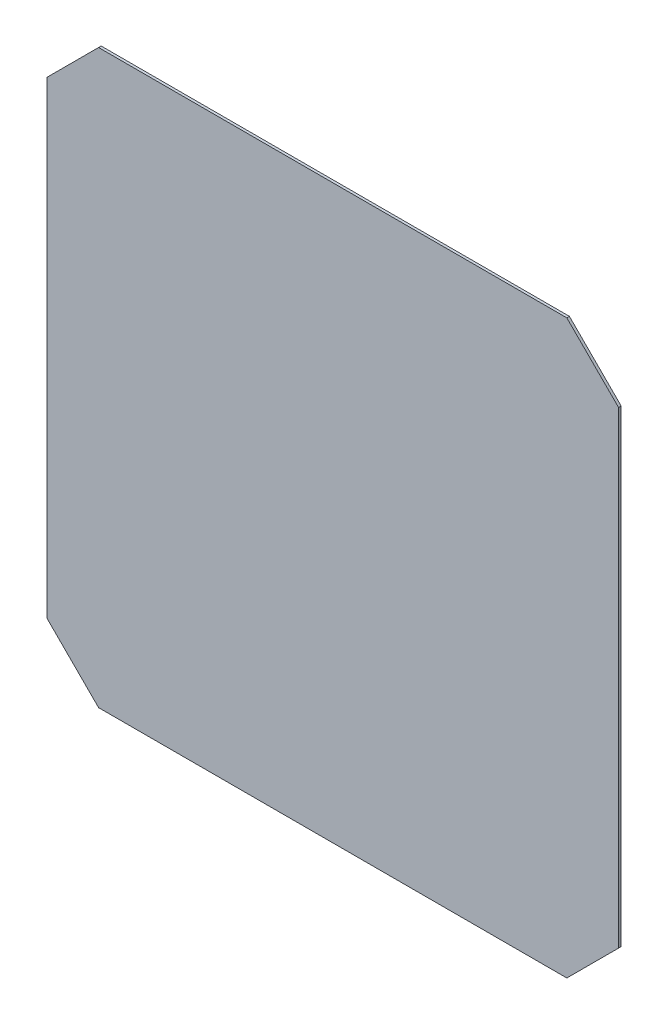
from build123d import *

# Parameters (mm, degrees)
EXTRUDE_1_DEPTH = 2


with BuildPart() as part:
    # 스케치1 → 보스-돌출1 (new body)
    with BuildSketch(Plane.XY):
        Polygon((-221, 181), (-181, 221), (181, 221), (221, 181), (221, -181), (181, -221), (-181, -221), (-221, -181), align=None)
    extrude(amount=EXTRUDE_1_DEPTH)


solid = part.part
